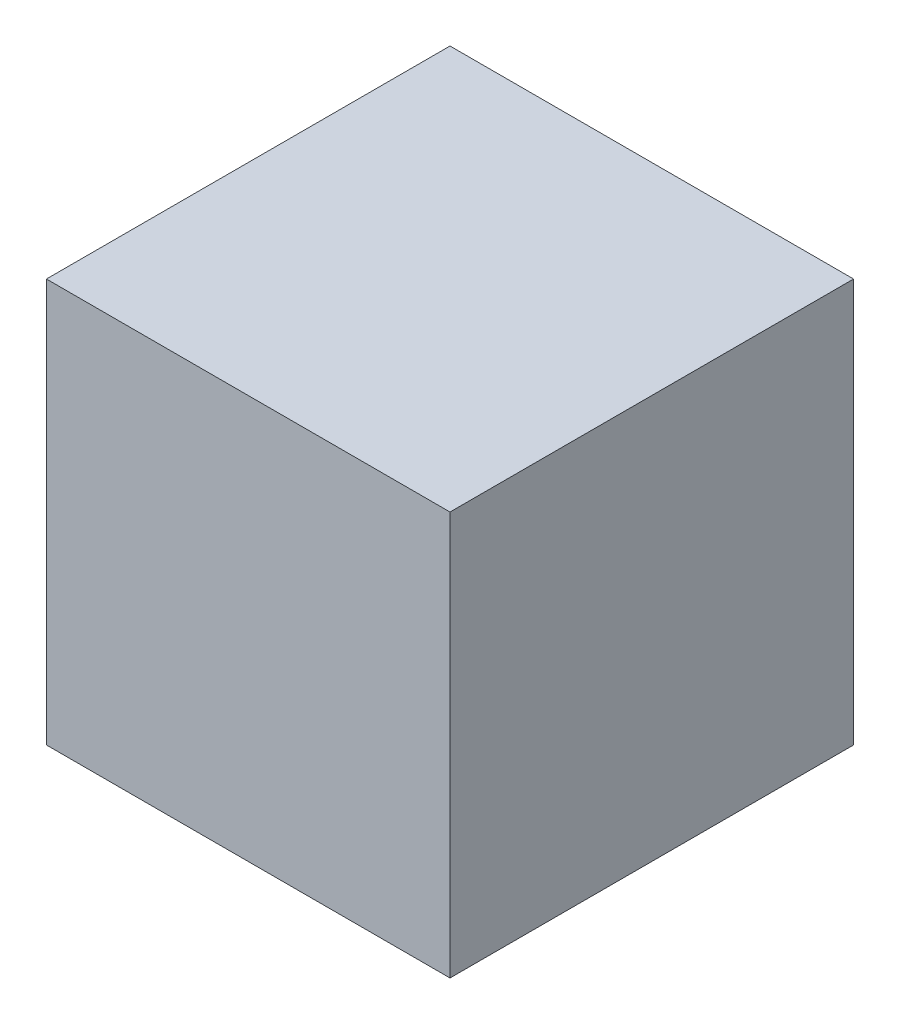
from build123d import *

# Parameters (mm, degrees)
SKETCH1_W           = 300
SKETCH1_H           = 300
BOSS_EXTRUDE1_DEPTH = 300


with BuildPart() as part:
    # Sketch1 → Boss-Extrude1 (new body)
    with BuildSketch(Plane.XY):
        Rectangle(SKETCH1_W, SKETCH1_H)
    extrude(amount=BOSS_EXTRUDE1_DEPTH)


solid = part.part
